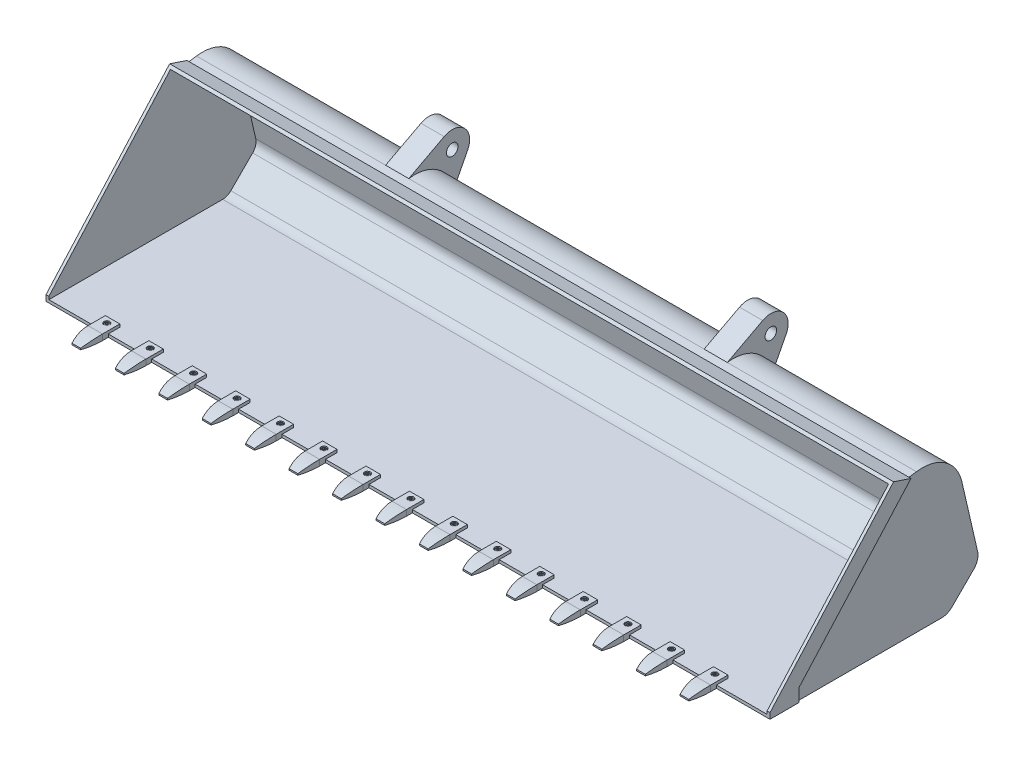
from build123d import *

# Parameters (mm, degrees)
BOSS_EXTRUDE1_DEPTH = 1250
CUT_EXTRUDE1_DEPTH  = 1240
CUT_EXTRUDE2_DEPTH  = 7
SKETCH5_R           = 20
BOSS_EXTRUDE2_DEPTH = 80
BOSS_EXTRUDE3_DEPTH = 25
SKETCH7_R           = 6
CUT_EXTRUDE3_DEPTH  = 21
SKETCH8_R           = 10
CUT_EXTRUDE4_DEPTH  = 10
SKETCH9_R           = 8.5
BOSS_EXTRUDE4_DEPTH = 8
FILLET1_R           = 1
SKETCH10_R          = 6
BOSS_EXTRUDE5_DEPTH = 8
CUT_EXTRUDE5_DEPTH  = 4
CUT_EXTRUDE6_DEPTH  = 553.223213355
LPATTERN1_COUNT     = 12
LPATTERN1_PITCH     = 150
LPATTERN2_COUNT     = 4
LPATTERN2_PITCH     = 150


with BuildPart() as part:
    # Sketch1 → Boss-Extrude1 (new body, symmetric)
    with BuildSketch(Plane(origin=(0, 0, 0), x_dir=(0, 0, -1), z_dir=(1, 0, 0))):
        with BuildLine():
            Line((126.95109792, 497.003258747), (-300, 20))
            Line((-300, 20), (-300, 0))
            Line((-300, 0), (300, 0))
            ThreePointArc((300, 0), (319.134171618, 3.806023374), (335.355339059, 14.644660941))
            Line((335.355339059, 14.644660941), (410.714444745, 90.003766626))
            ThreePointArc((410.714444745, 90.003766626), (423.422190482, 111.577237895), (424.077608925, 136.606658403))
            Line((424.077608925, 136.606658403), (369.336520796, 373.716360964))
            ThreePointArc((369.336520796, 373.716360964), (311.930141849, 457.800641996), (212.740940403, 480.760628429))
            Line((212.740940403, 480.760628429), (186.95109792, 477.003258747))
            Line((186.95109792, 477.003258747), (126.95109792, 497.003258747))
        make_face()
    extrude(amount=BOSS_EXTRUDE1_DEPTH, both=True)

    # Sketch3 → Cut-Extrude1 (cut, symmetric)
    with BuildSketch(Plane(origin=(0, 0, 0), x_dir=(0, 0, -1), z_dir=(1, 0, 0))):
        with BuildLine():
            Line((130.0210017, 485.439031953), (119.68432531, 488.88459075))
            Line((119.68432531, 488.88459075), (-308.950695621, 10))
            Line((-308.950695621, 10), (-290, 10))
            Line((-290, 10), (300, 10))
            ThreePointArc((300, 10), (315.307337295, 13.0448187), (328.284271247, 21.715728753))
            Line((328.284271247, 21.715728753), (403.643376933, 97.074834438))
            ThreePointArc((403.643376933, 97.074834438), (413.809573523, 114.333611453), (414.333908277, 134.357147859))
            Line((414.333908277, 134.357147859), (359.592820148, 371.46685042))
            ThreePointArc((359.592820148, 371.46685042), (306.28689684, 449.545111379), (214.182638355, 470.86509878))
            Line((214.182638355, 470.86509878), (186.04226833, 466.76527641))
            Line((186.04226833, 466.76527641), (130.0210017, 485.439031953))
        make_face()
    extrude(amount=CUT_EXTRUDE1_DEPTH, both=True, mode=Mode.SUBTRACT)

    # Sketch4 → Cut-Extrude2 (cut)
    with BuildSketch(Plane(origin=(1250, 0, 0), x_dir=(0, 0, -1), z_dir=(1, 0, 0))):
        with BuildLine():
            Line((186.95109792, 477.003258747), (-200, 44.689264047))
            Line((-200, 44.689264047), (-200, 0))
            Line((-200, 0), (300, 0))
            ThreePointArc((300, 0), (319.134171618, 3.806023374), (335.355339059, 14.644660941))
            Line((335.355339059, 14.644660941), (410.714444745, 90.003766626))
            ThreePointArc((410.714444745, 90.003766626), (423.422190482, 111.577237895), (424.077608925, 136.606658403))
            Line((424.077608925, 136.606658403), (369.336520796, 373.716360964))
            ThreePointArc((369.336520796, 373.716360964), (311.930141849, 457.800641996), (212.740940403, 480.760628429))
            Line((212.740940403, 480.760628429), (186.95109792, 477.003258747))
        make_face()
    cut_extrude2 = extrude(amount=-CUT_EXTRUDE2_DEPTH, mode=Mode.SUBTRACT)

    # Sketch5 → Boss-Extrude2 (add)
    with BuildSketch(Plane(origin=(590, 0, 0), x_dir=(0, 0, -1), z_dir=(1, 0, 0))):
        with BuildLine():
            Line((212.740940403, 480.760628429), (334.904691231, 545.278641461))
            ThreePointArc((334.904691231, 545.278641461), (405.140240757, 534.859455083), (416.255382614, 464.730677228))
            Line((416.255382614, 464.730677228), (369.336520796, 373.716360964))
            ThreePointArc((369.336520796, 373.716360964), (311.930141849, 457.800641996), (212.740940403, 480.760628429))
        make_face()
        with Locations((362.924711726, 492.223213355)):
            Circle(SKETCH5_R, mode=Mode.SUBTRACT)
    boss_extrude2 = extrude(amount=-BOSS_EXTRUDE2_DEPTH)

    # Mirror1: Cut-Extrude2, Boss-Extrude2 across plane
    add(cut_extrude2.mirror(Plane(origin=(0, 0, 0), x_dir=(0, 0, 1), z_dir=(1, 0, 0))), mode=Mode.SUBTRACT)
    add(boss_extrude2.mirror(Plane(origin=(0, 0, 0), x_dir=(0, 0, 1), z_dir=(1, 0, 0))))


with BuildPart() as body_2:
    # Sketch6 → Boss-Extrude3 (new body, symmetric)
    with BuildSketch(Plane(origin=(590, 0, 0), x_dir=(0, 0, -1), z_dir=(1, 0, 0))):
        with BuildLine():
            Line((-260, 20), (-260, 10))
            Line((-260, 10), (-300, 10))
            Line((-300, 10), (-300, 0))
            Line((-300, 0), (-385.383484153, 0))
            Line((-385.383484153, 0), (-385.383484153, 5))
            ThreePointArc((-385.383484153, 5), (-353.541019662, 16.201915172), (-320, 20))
            Line((-320, 20), (-260, 20))
        make_face()
    extrude(amount=BOSS_EXTRUDE3_DEPTH, both=True)


with BuildPart() as cut_extrude3_tool:
    # Sketch7 → Cut-Extrude3 (new body, through all)
    with BuildSketch(Plane(origin=(0, 20, 0), x_dir=(1, 0, 0), z_dir=(0, 1, 0))):
        with Locations((590, -280)):
            Circle(SKETCH7_R)
    extrude(amount=-CUT_EXTRUDE3_DEPTH)


with BuildPart() as part_1:
    add(part.part)

    # Cut-Extrude3: cut by cut_extrude3_tool
    add(cut_extrude3_tool.part, mode=Mode.SUBTRACT)


with BuildPart() as body_2_1:
    add(body_2.part)

    # Cut-Extrude3: cut by cut_extrude3_tool
    add(cut_extrude3_tool.part, mode=Mode.SUBTRACT)

    # Sketch8 → Cut-Extrude4 (cut)
    with BuildSketch(Plane(origin=(0, 20, 0), x_dir=(1, 0, 0), z_dir=(0, 1, 0))):
        with Locations((590, -280)):
            Circle(SKETCH8_R)
    extrude(amount=-CUT_EXTRUDE4_DEPTH, mode=Mode.SUBTRACT)

    # Sketch12 → Cut-Extrude6 (cut, through all)
    with BuildSketch(Plane.XZ):
        with BuildLine():
            Line((615, 320), (624.51879793, 320))
            Line((624.51879793, 320), (624.51879793, 397.123154303))
            Line((624.51879793, 397.123154303), (555.270280427, 397.123154303))
            Line((555.270280427, 397.123154303), (555.270280427, 320))
            Line((555.270280427, 320), (565, 320))
            ThreePointArc((565, 320), (567.51445135, 353.071891388), (575, 385.383484153))
            Line((575, 385.383484153), (605, 385.383484153))
            ThreePointArc((605, 385.383484153), (612.48554865, 353.071891388), (615, 320))
        make_face()
    extrude(amount=-CUT_EXTRUDE6_DEPTH, mode=Mode.SUBTRACT)


with BuildPart() as body_3:
    # Sketch9 → Boss-Extrude4 (new body)
    with BuildSketch(Plane(origin=(0, 10, 0), x_dir=(1, 0, 0), z_dir=(0, 1, 0))):
        with Locations((590, -280)):
            Circle(SKETCH9_R)
    extrude(amount=BOSS_EXTRUDE4_DEPTH)

    # Fillet1
    fillet1_edges = [body_3.edges().sort_by_distance(p)[0] for p in [
        (581.5, 18, 280),
    ]]
    fillet(fillet1_edges, radius=FILLET1_R)

    # Sketch10 → Boss-Extrude5 (add)
    with BuildSketch(Plane(origin=(0, 10, 0), x_dir=(1, 0, 0), z_dir=(0, 1, 0))):
        with Locations((590, -280)):
            Circle(SKETCH10_R)
    extrude(amount=-BOSS_EXTRUDE5_DEPTH)

    # Sketch11 → Cut-Extrude5 (cut)
    with BuildSketch(Plane(origin=(0, 18, 0), x_dir=(1, 0, 0), z_dir=(0, 1, 0))):
        Polygon((587.408706467, -284.851308878), (592.905709963, -284.669780467), (595.497003496, -279.818471589), (592.591293533, -275.148691122), (587.094290037, -275.330219533), (584.502996504, -280.181528411), align=None)
    extrude(amount=-CUT_EXTRUDE5_DEPTH, mode=Mode.SUBTRACT)


with BuildPart() as lpattern1_1:
    # LPattern1: pattern copy
    add(body_3.part.moved(Location(Vector(-1, 0, 0) * (1 * LPATTERN1_PITCH))))


with BuildPart() as lpattern1_2:
    # LPattern1: pattern copy
    add(body_3.part.moved(Location(Vector(-1, 0, 0) * (2 * LPATTERN1_PITCH))))


with BuildPart() as lpattern1_3:
    # LPattern1: pattern copy
    add(body_3.part.moved(Location(Vector(-1, 0, 0) * (3 * LPATTERN1_PITCH))))


with BuildPart() as lpattern1_4:
    # LPattern1: pattern copy
    add(body_3.part.moved(Location(Vector(-1, 0, 0) * (4 * LPATTERN1_PITCH))))


with BuildPart() as lpattern1_5:
    # LPattern1: pattern copy
    add(body_3.part.moved(Location(Vector(-1, 0, 0) * (5 * LPATTERN1_PITCH))))


with BuildPart() as lpattern1_6:
    # LPattern1: pattern copy
    add(body_3.part.moved(Location(Vector(-1, 0, 0) * (6 * LPATTERN1_PITCH))))


with BuildPart() as lpattern1_7:
    # LPattern1: pattern copy
    add(body_3.part.moved(Location(Vector(-1, 0, 0) * (7 * LPATTERN1_PITCH))))


with BuildPart() as lpattern1_8:
    # LPattern1: pattern copy
    add(body_3.part.moved(Location(Vector(-1, 0, 0) * (8 * LPATTERN1_PITCH))))


with BuildPart() as lpattern1_9:
    # LPattern1: pattern copy
    add(body_3.part.moved(Location(Vector(-1, 0, 0) * (9 * LPATTERN1_PITCH))))


with BuildPart() as lpattern1_10:
    # LPattern1: pattern copy
    add(body_3.part.moved(Location(Vector(-1, 0, 0) * (10 * LPATTERN1_PITCH))))


with BuildPart() as lpattern1_11:
    # LPattern1: pattern copy
    add(body_3.part.moved(Location(Vector(-1, 0, 0) * (11 * LPATTERN1_PITCH))))


with BuildPart() as lpattern1_12:
    # LPattern1: pattern copy
    add(body_2_1.part.moved(Location(Vector(-1, 0, 0) * (1 * LPATTERN1_PITCH))))


with BuildPart() as lpattern1_13:
    # LPattern1: pattern copy
    add(body_2_1.part.moved(Location(Vector(-1, 0, 0) * (2 * LPATTERN1_PITCH))))


with BuildPart() as lpattern1_14:
    # LPattern1: pattern copy
    add(body_2_1.part.moved(Location(Vector(-1, 0, 0) * (3 * LPATTERN1_PITCH))))


with BuildPart() as lpattern1_15:
    # LPattern1: pattern copy
    add(body_2_1.part.moved(Location(Vector(-1, 0, 0) * (4 * LPATTERN1_PITCH))))


with BuildPart() as lpattern1_16:
    # LPattern1: pattern copy
    add(body_2_1.part.moved(Location(Vector(-1, 0, 0) * (5 * LPATTERN1_PITCH))))


with BuildPart() as lpattern1_17:
    # LPattern1: pattern copy
    add(body_2_1.part.moved(Location(Vector(-1, 0, 0) * (6 * LPATTERN1_PITCH))))


with BuildPart() as lpattern1_18:
    # LPattern1: pattern copy
    add(body_2_1.part.moved(Location(Vector(-1, 0, 0) * (7 * LPATTERN1_PITCH))))


with BuildPart() as lpattern1_19:
    # LPattern1: pattern copy
    add(body_2_1.part.moved(Location(Vector(-1, 0, 0) * (8 * LPATTERN1_PITCH))))


with BuildPart() as lpattern1_20:
    # LPattern1: pattern copy
    add(body_2_1.part.moved(Location(Vector(-1, 0, 0) * (9 * LPATTERN1_PITCH))))


with BuildPart() as lpattern1_21:
    # LPattern1: pattern copy
    add(body_2_1.part.moved(Location(Vector(-1, 0, 0) * (10 * LPATTERN1_PITCH))))


with BuildPart() as lpattern1_22:
    # LPattern1: pattern copy
    add(body_2_1.part.moved(Location(Vector(-1, 0, 0) * (11 * LPATTERN1_PITCH))))


with BuildPart() as lpattern2_1:
    # LPattern2: pattern copy
    add(body_3.part.moved(Location(Vector(1, 0, 0) * (1 * LPATTERN2_PITCH))))


with BuildPart() as lpattern2_2:
    # LPattern2: pattern copy
    add(body_3.part.moved(Location(Vector(1, 0, 0) * (2 * LPATTERN2_PITCH))))


with BuildPart() as lpattern2_3:
    # LPattern2: pattern copy
    add(body_3.part.moved(Location(Vector(1, 0, 0) * (3 * LPATTERN2_PITCH))))


with BuildPart() as lpattern2_4:
    # LPattern2: pattern copy
    add(body_2_1.part.moved(Location(Vector(1, 0, 0) * (1 * LPATTERN2_PITCH))))


with BuildPart() as lpattern2_5:
    # LPattern2: pattern copy
    add(body_2_1.part.moved(Location(Vector(1, 0, 0) * (2 * LPATTERN2_PITCH))))


with BuildPart() as lpattern2_6:
    # LPattern2: pattern copy
    add(body_2_1.part.moved(Location(Vector(1, 0, 0) * (3 * LPATTERN2_PITCH))))


solid = Compound([part_1.part, body_2_1.part, body_3.part, lpattern1_1.part, lpattern1_2.part, lpattern1_3.part, lpattern1_4.part, lpattern1_5.part, lpattern1_6.part, lpattern1_7.part, lpattern1_8.part, lpattern1_9.part, lpattern1_10.part, lpattern1_11.part, lpattern1_12.part, lpattern1_13.part, lpattern1_14.part, lpattern1_15.part, lpattern1_16.part, lpattern1_17.part, lpattern1_18.part, lpattern1_19.part, lpattern1_20.part, lpattern1_21.part, lpattern1_22.part, lpattern2_1.part, lpattern2_2.part, lpattern2_3.part, lpattern2_4.part, lpattern2_5.part, lpattern2_6.part])
